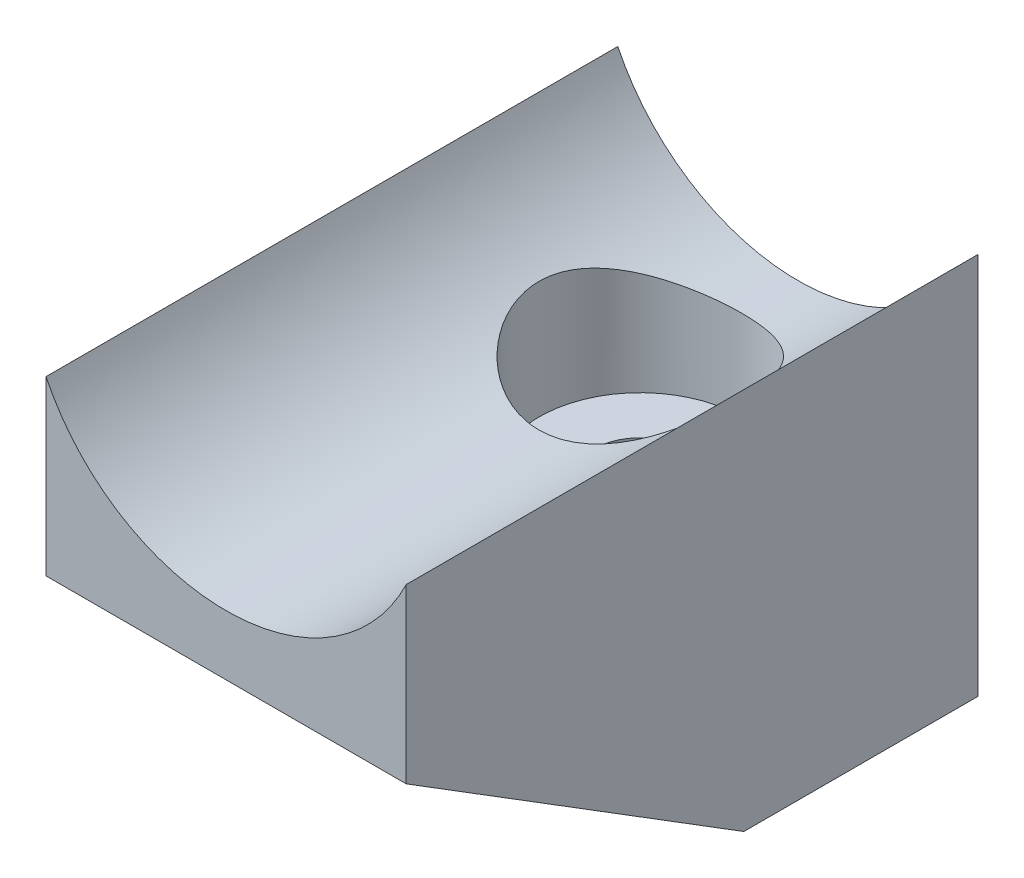
from build123d import *

# Parameters (mm, degrees)
BOSS_EXTRUDE1_DEPTH = 76.2
CUT_EXTRUDE1_DEPTH  = 49.2
SKETCH5_R           = 6.15
CUT_EXTRUDE2_DEPTH  = 44
SKETCH6_R           = 13.5
CUT_EXTRUDE3_DEPTH  = 27


with BuildPart() as part:
    # Sketch2 → Boss-Extrude1 (new body)
    with BuildSketch(Plane.XY):
        with BuildLine():
            Line((0, 51), (0, 0))
            Line((0, 0), (48, 0))
            Line((48, 0), (48, 51))
            ThreePointArc((48, 51), (24, 35.983160819), (0, 51))
        make_face()
    extrude(amount=BOSS_EXTRUDE1_DEPTH)

    # Sketch3 → Cut-Extrude1 (cut)
    with BuildSketch(Plane.ZY.offset(-48)):
        Polygon((76.2, 28), (76.2, 0), (31.2, 0), align=None)
    extrude(amount=CUT_EXTRUDE1_DEPTH, mode=Mode.SUBTRACT)

    # Sketch5 → Cut-Extrude2 (cut)
    with BuildSketch(Plane.XZ):
        with Locations((24, 21)):
            Circle(SKETCH5_R)
    extrude(amount=-CUT_EXTRUDE2_DEPTH, mode=Mode.SUBTRACT)

    # Sketch6 → Cut-Extrude3 (cut)
    with BuildSketch(Plane(origin=(0, 51, 0), x_dir=(-1, 0, 0), z_dir=(0, -1, 0))):
        with Locations((-24, -21)):
            Circle(SKETCH6_R)
    extrude(amount=CUT_EXTRUDE3_DEPTH, mode=Mode.SUBTRACT)


solid = part.part
